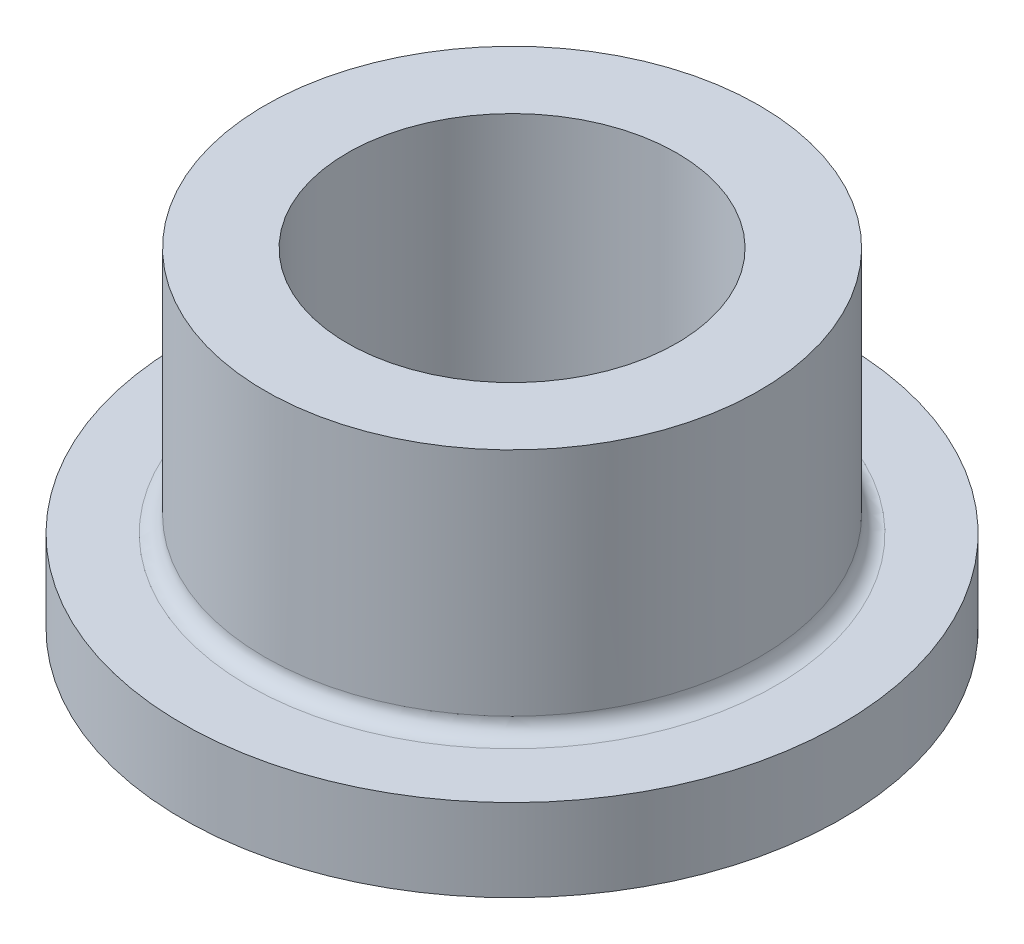
from build123d import *

# Parameters (mm, degrees)
FILLET1_R = 0.4


with BuildPart() as part:
    # Sketch1 → Revolve1 (revolve)
    with BuildSketch(Plane(origin=(0, 0, 0), x_dir=(0, 0, -1), z_dir=(1, 0, 0))):
        Polygon((4, 8), (4, 0), (8, 0), (8, 2), (6, 2), (6, 8), align=None)
    revolve(axis=Axis((0, 0, 0), (0, 1, 0)))

    # Fillet1
    fillet1_edges = [part.edges().sort_by_distance(p)[0] for p in [
        (0, 2, 6),
    ]]
    fillet(fillet1_edges, radius=FILLET1_R)


solid = part.part
